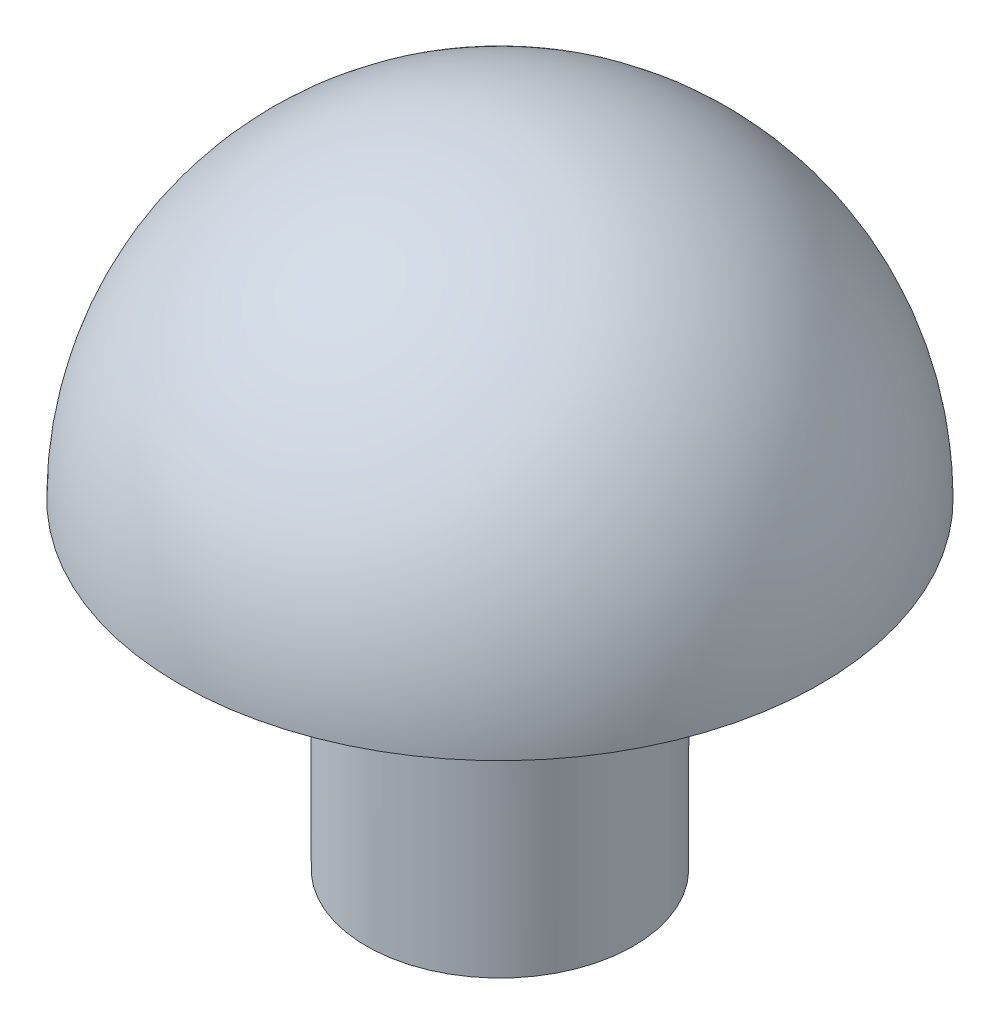
from build123d import *

# Parameters (mm, degrees)
SKETCH1_R           = 2.5
BOSS_EXTRUDE1_DEPTH = 3
REVOLVE1_ANGLE      = 180
SKETCH3_R           = 2.5
BOSS_EXTRUDE2_DEPTH = 3


with BuildPart() as part:
    # Sketch1 → Boss-Extrude1 (new body)
    with BuildSketch(Plane(origin=(0, 0, 0), x_dir=(1, 0, 0), z_dir=(0, 1, 0))):
        Circle(SKETCH1_R)
    extrude(amount=BOSS_EXTRUDE1_DEPTH)

    # Sketch2 → Revolve1 (revolve)
    with BuildSketch(Plane(origin=(0, 3, 0), x_dir=(1, 0, 0), z_dir=(0, 1, 0))):
        with BuildLine():
            Line((0, -6), (0, 6))
            ThreePointArc((0, 6), (6, 0), (0, -6))
        make_face()
    revolve(axis=Axis((0, 3, 6), (0, 0, 1)), revolution_arc=REVOLVE1_ANGLE)

    # Sketch3 → Boss-Extrude2 (add)
    with BuildSketch(Plane.XZ):
        Circle(SKETCH3_R)
    extrude(amount=BOSS_EXTRUDE2_DEPTH)


solid = part.part
